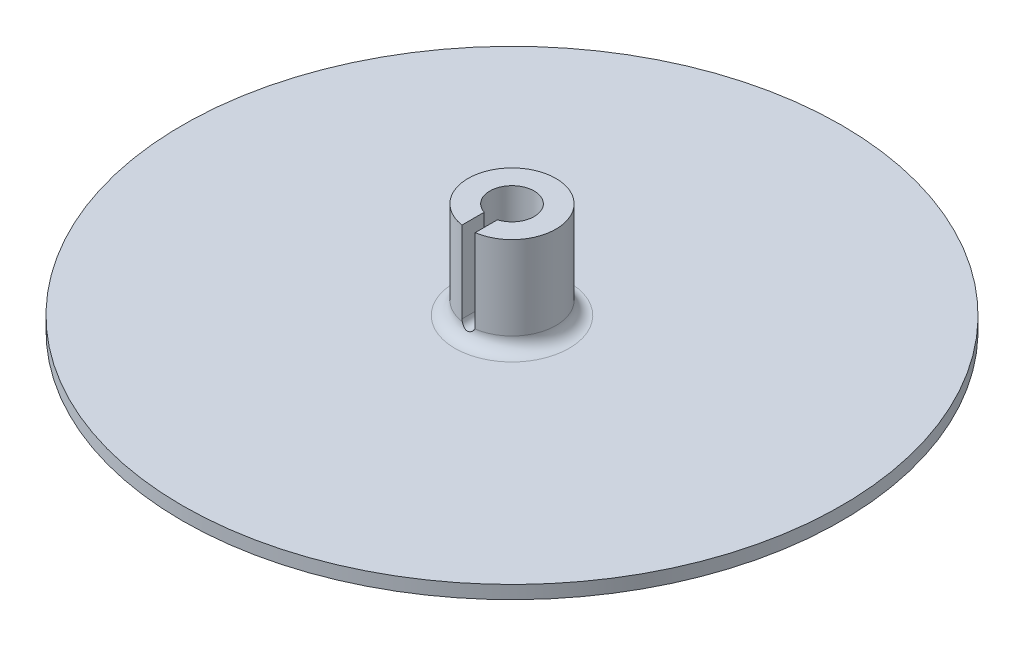
from build123d import *

# Parameters (mm, degrees)
SKETCH1_R                                            = 75
BOSS_EXTRUDE1_DEPTH                                  = 3
SKETCH2_R                                            = 10
SKETCH2_R_2                                          = 5.05
BOSS_EXTRUDE2_DEPTH                                  = 22
FILLET1_R                                            = 3
CUT_EXTRUDE1_DEPTH                                   = 76
CSK_FOR_M3_HEX_SOCKET_COUNTERSUNK_HEAD_S_D           = 3.6
CSK_FOR_M3_HEX_SOCKET_COUNTERSUNK_HEAD_S_CSINK_D     = 6.94
CSK_FOR_M3_HEX_SOCKET_COUNTERSUNK_HEAD_S_CSINK_ANGLE = 90


with BuildPart() as part:
    # Sketch1 → Boss-Extrude1 (new body)
    with BuildSketch(Plane(origin=(0, 0, 0), x_dir=(1, 0, 0), z_dir=(0, 1, 0))):
        Circle(SKETCH1_R)
    extrude(amount=BOSS_EXTRUDE1_DEPTH)

    # Sketch2 → Boss-Extrude2 (add)
    with BuildSketch(Plane(origin=(0, 3, 0), x_dir=(1, 0, 0), z_dir=(0, 1, 0))):
        Circle(SKETCH2_R)
        Circle(SKETCH2_R_2, mode=Mode.SUBTRACT)
    extrude(amount=BOSS_EXTRUDE2_DEPTH)

    # Fillet1
    fillet1_edges = [part.edges().sort_by_distance(p)[0] for p in [
        (-10, 3, 0),
    ]]
    fillet(fillet1_edges, radius=FILLET1_R)

    # Sketch3 → Cut-Extrude1 (cut, through all)
    with BuildSketch(Plane.XY):
        with BuildLine():
            Line((1.5, 25), (1.5, 6.5))
            ThreePointArc((1.5, 6.5), (0, 5), (-1.5, 6.5))
            Line((-1.5, 6.5), (-1.5, 25))
            ThreePointArc((-1.5, 25), (0, 26.5), (1.5, 25))
        make_face()
    extrude(amount=CUT_EXTRUDE1_DEPTH, mode=Mode.SUBTRACT)

    # CSK for M3 Hex Socket Countersunk Head Screw1 (through all)
    with Locations(Plane(origin=(0, 0, 0), x_dir=(-1, 0, 0), z_dir=(0, -1, 0))):
        with Locations((0, 0)):
            CounterSinkHole(CSK_FOR_M3_HEX_SOCKET_COUNTERSUNK_HEAD_S_D / 2, CSK_FOR_M3_HEX_SOCKET_COUNTERSUNK_HEAD_S_CSINK_D / 2, counter_sink_angle=CSK_FOR_M3_HEX_SOCKET_COUNTERSUNK_HEAD_S_CSINK_ANGLE)


solid = part.part
